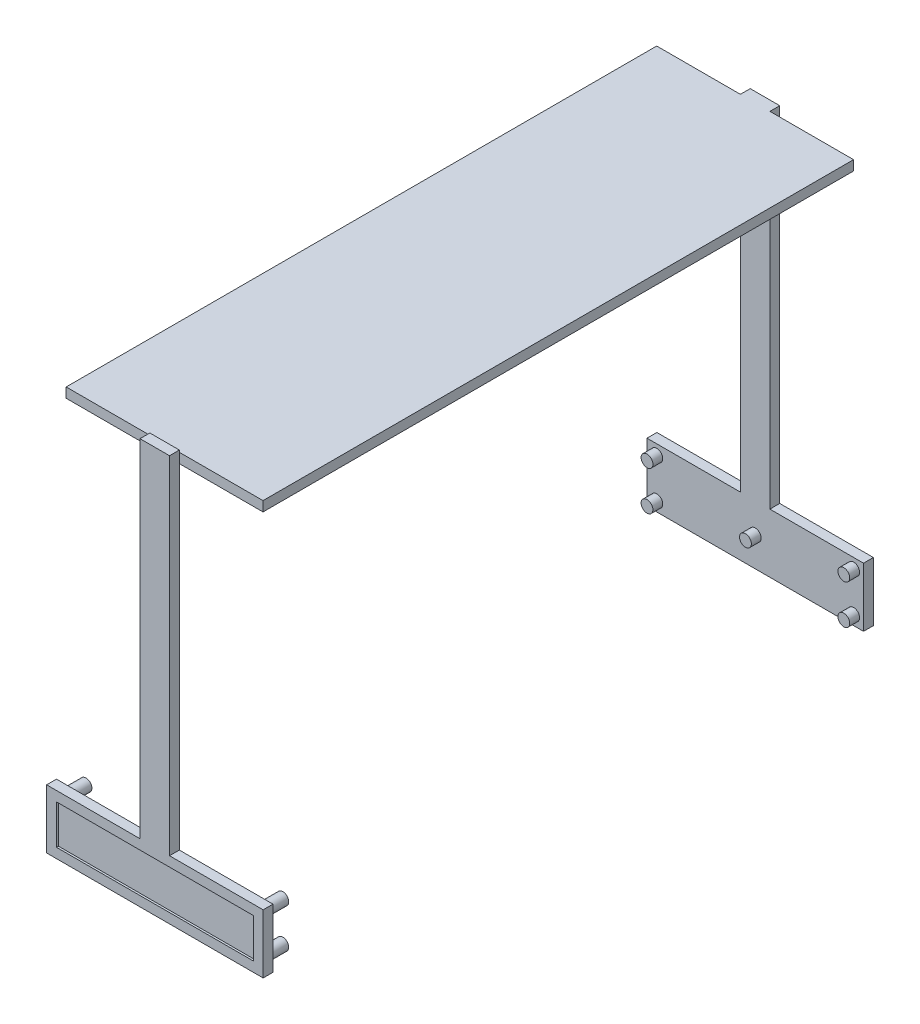
from build123d import *

# Parameters (mm, degrees)
SKETCH2_W            = 110
SKETCH2_H            = 30
SKETCH2_W_2          = 100
SKETCH2_H_2          = 20
BOSS_EXTRUDE1_DEPTH  = 5
SKETCH3_R            = 2.446699787
CUT_EXTRUDE3_DEPTH   = 15
SKETCH3_10_W         = 15
SKETCH3_10_H         = 5
SKETCH3_10_R         = 2.446699787
BOSS_EXTRUDE4_DEPTH  = 175
SKETCH12_W           = 100
SKETCH12_H           = 20
BOSS_EXTRUDE12_DEPTH = 1
SKETCH5_W            = 15
SKETCH5_H            = 5
BOSS_EXTRUDE13_DEPTH = 300
SKETCH13_R           = 2
CUT_EXTRUDE10_DEPTH  = 301
BOSS_EXTRUDE16_DEPTH = 205
SKETCH22_R           = 3
BOSS_EXTRUDE20_DEPTH = 10
SKETCH26_W           = 110
SKETCH26_H           = 30
BOSS_EXTRUDE22_DEPTH = 5
SKETCH27_R           = 3
BOSS_EXTRUDE23_DEPTH = 5
SKETCH28_W           = 28
SKETCH28_H           = 35
SKETCH28_W_2         = 25
SKETCH28_H_2         = 32
BOSS_EXTRUDE26_DEPTH = 7
BOSS_EXTRUDE28_DEPTH = 42.5
BOSS_EXTRUDE29_DEPTH = 57.5
BOSS_EXTRUDE30_DEPTH = 1
SKETCH30_R           = 0.6
BOSS_EXTRUDE32_DEPTH = 7.5
BOSS_EXTRUDE34_DEPTH = 3


with BuildPart() as part:
    # Sketch2 → Boss-Extrude1 (new body)
    with BuildSketch(Plane.XY):
        Rectangle(SKETCH2_W, SKETCH2_H)
        Rectangle(SKETCH2_W_2, SKETCH2_H_2, mode=Mode.SUBTRACT)
    extrude(amount=BOSS_EXTRUDE1_DEPTH)

    # Sketch3 → Cut-Extrude3 (cut)
    with BuildSketch(Plane(origin=(0, 15, 0), x_dir=(1, 0, 0), z_dir=(0, 1, 0))):
        with Locations(Location((4.931689359, -2.5, 0), (0, 0, 180))):
            Circle(SKETCH3_R)
        with Locations(Location((-0.068310641, -2.5, 0), (0, 0, 180))):
            Circle(SKETCH3_R)
        with Locations(Location((-5.068310641, -2.5, 0), (0, 0, 180))):
            Circle(SKETCH3_R)
    extrude(amount=-CUT_EXTRUDE3_DEPTH, mode=Mode.SUBTRACT)

    # Sketch3_10 → Boss-Extrude4 (add)
    with BuildSketch(Plane(origin=(0, 15, 0), x_dir=(1, 0, 0), z_dir=(0, 1, 0))):
        with Locations((-0.068310641, -2.5)):
            Rectangle(SKETCH3_10_W, SKETCH3_10_H)
        with Locations(Location((-0.068310641, -2.5, 0), (0, 0, 180))):
            Circle(SKETCH3_10_R, mode=Mode.SUBTRACT)
        with Locations(Location((4.931689359, -2.5, 0), (0, 0, 180))):
            Circle(SKETCH3_10_R, mode=Mode.SUBTRACT)
        with Locations(Location((-5.068310641, -2.5, 0), (0, 0, 180))):
            Circle(SKETCH3_10_R, mode=Mode.SUBTRACT)
    extrude(amount=BOSS_EXTRUDE4_DEPTH)

    # Sketch12 → Boss-Extrude12 (add)
    with BuildSketch(Plane(origin=(0, 0, 0), x_dir=(-1, 0, 0), z_dir=(0, 0, -1))):
        Rectangle(SKETCH12_W, SKETCH12_H)
    extrude(amount=-BOSS_EXTRUDE12_DEPTH)

    # Sketch5 → Boss-Extrude13 (add)
    with BuildSketch(Plane(origin=(0, 0, 0), x_dir=(-1, 0, 0), z_dir=(0, 0, -1))):
        with Locations((0.068310641, 187.5)):
            Rectangle(SKETCH5_W, SKETCH5_H)
    extrude(amount=BOSS_EXTRUDE13_DEPTH)

    # Sketch13 → Cut-Extrude10 (cut)
    with BuildSketch(Plane(origin=(0, 0, -300), x_dir=(-1, 0, 0), z_dir=(0, 0, -1))):
        with Locations((-4.931689359, 187.5)):
            Circle(SKETCH13_R)
        with Locations((0.068310641, 187.5)):
            Circle(SKETCH13_R)
        with Locations((5.068310641, 187.5)):
            Circle(SKETCH13_R)
    extrude(amount=-CUT_EXTRUDE10_DEPTH, mode=Mode.SUBTRACT)

    # 3DSketch1 → Boss-Extrude16 (add)
    with BuildSketch(Plane(origin=(-7.568310641, 190, -300), x_dir=(0.9486832980505138, 0, -0.3162277660168382), z_dir=(0, -1, 0))):
        Polygon((0, 0), (14.230249471, 4.74341649), (15.811388301, 0), (1.58113883, -4.74341649), align=None)
    extrude(amount=BOSS_EXTRUDE16_DEPTH)

    # Sketch22 → Boss-Extrude20 (add)
    with BuildSketch(Plane(origin=(0, 0, 0), x_dir=(-1, 0, 0), z_dir=(0, 0, -1))):
        with BuildLine():
            ThreePointArc((-50, -7), (-52.121320344, -12.121320344), (-47, -10))
            Line((-47, -10), (-50, -10))
            Line((-50, -10), (-50, -7))
        make_face()
        with BuildLine():
            Line((-50, -10), (-47, -10))
            ThreePointArc((-47, -10), (-47.878679656, -7.878679656), (-50, -7))
            Line((-50, -7), (-50, -10))
        make_face()
        with Locations(Location((0, 0, 0), (0, 0, 180))):
            Circle(SKETCH22_R)
        with Locations(Location((-50, 10, 0), (0, 0, 180))):
            Circle(SKETCH22_R)
        with Locations(Location((50, 10, 0), (0, 0, 180))):
            Circle(SKETCH22_R)
        with Locations(Location((50, -10, 0), (0, 0, 180))):
            Circle(SKETCH22_R)
    extrude(amount=BOSS_EXTRUDE20_DEPTH)

    # Sketch26 → Boss-Extrude22 (add)
    with BuildSketch(Plane(origin=(0, 0, -305), x_dir=(-1, 0, 0), z_dir=(0, 0, -1))):
        Rectangle(SKETCH26_W, SKETCH26_H)
    extrude(amount=-BOSS_EXTRUDE22_DEPTH)

    # Sketch27 → Boss-Extrude23 (add)
    with BuildSketch(Plane.XY.offset(-300)):
        Circle(SKETCH27_R)
        with Locations((-50, 10)):
            Circle(SKETCH27_R)
        with Locations((-50, -10)):
            Circle(SKETCH27_R)
        with Locations((50, 10)):
            Circle(SKETCH27_R)
        with Locations((50, -10)):
            Circle(SKETCH27_R)
    extrude(amount=BOSS_EXTRUDE23_DEPTH)

    # Sketch28 → Boss-Extrude26 (add)
    with BuildSketch(Plane.XZ.offset(-185)):
        with Locations((-0.068310641, -150)):
            Rectangle(SKETCH28_W, SKETCH28_H)
        with Locations((0.231689359, -150)):
            Rectangle(SKETCH28_W_2, SKETCH28_H_2, mode=Mode.SUBTRACT)
        with Locations((-0.068310641, -235)):
            Rectangle(SKETCH28_W, SKETCH28_H)
        with Locations((0.231689359, -235)):
            Rectangle(SKETCH28_W_2, SKETCH28_H_2, mode=Mode.SUBTRACT)
        with Locations((-0.068310641, -65)):
            Rectangle(SKETCH28_W, SKETCH28_H)
        with Locations((0.231689359, -65)):
            Rectangle(SKETCH28_W_2, SKETCH28_H_2, mode=Mode.SUBTRACT)
    extrude(amount=BOSS_EXTRUDE26_DEPTH)

    # 3DSketch4 → Boss-Extrude28 (add)
    with BuildSketch(Plane(origin=(-7.568310641, 185, -300), x_dir=(0, 0.01666435233399335, 0.9998611400396), z_dir=(-1, 0, 0))):
        Polygon((0, 0), (0.083321762, 4.9993057), (300.041663774, 0), (299.958342012, -4.9993057), align=None)
    extrude(amount=BOSS_EXTRUDE28_DEPTH)

    # 3DSketch4_4 → Boss-Extrude29 (add)
    with BuildSketch(Plane(origin=(-7.568310641, 185, -300), x_dir=(0, 0.01666435233399335, 0.9998611400396), z_dir=(-1, 0, 0))):
        Polygon((0, 0), (0.083321762, 4.9993057), (300.041663774, 0), (299.958342012, -4.9993057), align=None)
    extrude(amount=-BOSS_EXTRUDE29_DEPTH)

    # 3DSketch5 → Boss-Extrude30 (add)
    with BuildSketch(Plane(origin=(-7.568310641, 190, 5), x_dir=(0.9486832980505139, 0, -0.31622776601683783), z_dir=(0, 1, 0))):
        Polygon((0, 0), (1.58113883, 4.74341649), (15.811388301, 0), (14.230249471, -4.74341649), align=None)
    extrude(amount=BOSS_EXTRUDE30_DEPTH)

    # Sketch30 → Boss-Extrude32 (add)
    with BuildSketch(Plane.XZ.offset(-185)):
        with Locations(Location((-9.923310641, -248.1916, 0), (0, 0, 90))):
            Circle(SKETCH30_R)
        with Locations(Location((10.386689359, -248.1916, 0), (0, 0, 90))):
            Circle(SKETCH30_R)
        with Locations(Location((-9.923310641, -222.0016, 0), (0, 0, 90))):
            Circle(SKETCH30_R)
        with Locations(Location((10.386689359, -222.0016, 0), (0, 0, 90))):
            Circle(SKETCH30_R)
        with Locations(Location((10.462158109, -163.095, 0), (0, 0, 90))):
            Circle(SKETCH30_R)
        with Locations(Location((-9.847841891, -163.095, 0), (0, 0, 90))):
            Circle(SKETCH30_R)
        with Locations(Location((-9.847841891, -136.905, 0), (0, 0, 90))):
            Circle(SKETCH30_R)
        with Locations(Location((10.462158109, -136.905, 0), (0, 0, 90))):
            Circle(SKETCH30_R)
        with Locations(Location((10.462158109, -51.905, 0), (0, 0, 90))):
            Circle(SKETCH30_R)
        with Locations(Location((-9.847841891, -51.905, 0), (0, 0, 90))):
            Circle(SKETCH30_R)
        with Locations(Location((-9.847841891, -78.095, 0), (0, 0, 90))):
            Circle(SKETCH30_R)
        with Locations(Location((10.462158109, -78.095, 0), (0, 0, 90))):
            Circle(SKETCH30_R)
    extrude(amount=BOSS_EXTRUDE32_DEPTH)

    # 3DSketch6 → Boss-Extrude34 (add)
    with BuildSketch(Plane(origin=(-50, 10, 1), x_dir=(0.9805806756909201, -0.19611613513818413, 0), z_dir=(0, 0, 1))):
        Polygon((0, 0), (98.058067569, 19.611613514), (101.980390272, 0), (3.922322703, -19.611613514), align=None)
    extrude(amount=BOSS_EXTRUDE34_DEPTH)


solid = part.part
